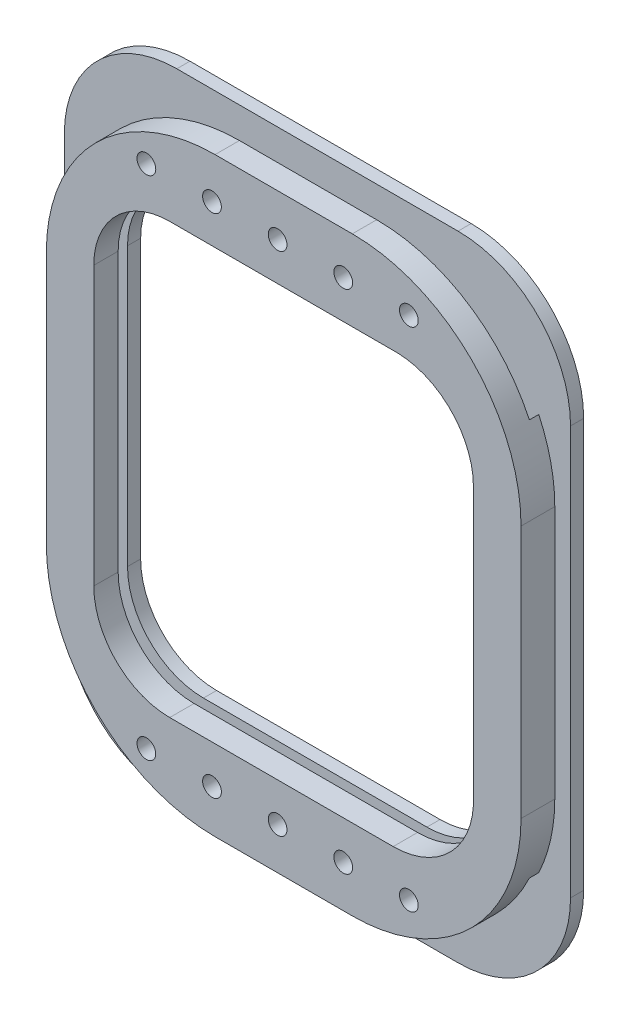
from build123d import *

# Parameters (mm, degrees)
BOSS_EXTRUDE1_DEPTH       = 63.5
SKETCH4_W                 = 299.849109537
SKETCH4_H                 = 429.26
CUT_EXTRUDE2_DEPTH        = 5.08
CUT_EXTRUDE2_DEPTH_BACK   = 1.27
CUT_EXTRUDE4_DEPTH        = 25.4
CUT_EXTRUDE5_START        = -1
SKETCH10_R                = 6.35
CUT_EXTRUDE5_DEPTH        = 120.38
LPATTERN1_COUNT           = 5
LPATTERN1_PITCH           = 44.45
MIRROR1_START             = -1
MIRROR1_COPY_1_SKETCH_R   = 6.35
MIRROR1_COPY_1_DEPTH      = 120.38
MIRROR1_COPY_2_SKETCH_R   = 6.35
MIRROR1_COPY_2_DEPTH      = 120.38
MIRROR1_COPY_3_SKETCH_R   = 6.35
MIRROR1_COPY_3_DEPTH      = 120.38
MIRROR1_COPY_4_SKETCH_R   = 6.35
MIRROR1_COPY_4_DEPTH      = 120.38
SKETCH11_W                = 361.999881137
SKETCH11_H                = 453.321085271
CUT_EXTRUDE6_DEPTH        = 32.75
SKETCH13_R                = 6.355145043
BOSS_EXTRUDE2_DEPTH       = 7.62
REVOLVE1_ANGLE            = 180
LPATTERN2_COUNT           = 5
LPATTERN2_PITCH           = 44.45
LPATTERN3_COUNT           = 2
LPATTERN3_PITCH           = 342.9
LPATTERN3_COPY_1_SKETCH_R = 6.355145043
LPATTERN3_COPY_1_DEPTH    = 7.62
LPATTERN3_COPY_2_SKETCH_R = 6.355145043
LPATTERN3_COPY_2_DEPTH    = 7.62
LPATTERN3_COPY_3_SKETCH_R = 6.355145043
LPATTERN3_COPY_3_DEPTH    = 7.62
LPATTERN3_COPY_4_SKETCH_R = 6.355145043
LPATTERN3_COPY_4_DEPTH    = 7.62
LPATTERN3_COPY_5_ANGLE    = 180
LPATTERN3_COPY_6_ANGLE    = 180
LPATTERN3_COPY_7_ANGLE    = 180
LPATTERN3_COPY_8_ANGLE    = 180


with BuildPart() as part:
    # Sketch1 → Boss-Extrude1 (new body)
    with BuildSketch(Plane.XY):
        with BuildLine():
            Line((69.204322144, 274.429330483), (259.704322144, 274.429330483))
            ThreePointArc((259.704322144, 274.429330483), (313.58585887, 252.11086721), (335.904322144, 198.229330483))
            Line((335.904322144, 198.229330483), (335.904322144, -78.630669517))
            ThreePointArc((335.904322144, -78.630669517), (313.58585887, -132.512206243), (259.704322144, -154.830669517))
            Line((259.704322144, -154.830669517), (69.204322144, -154.830669517))
            ThreePointArc((69.204322144, -154.830669517), (15.322785417, -132.512206243), (-6.995677856, -78.630669517))
            Line((-6.995677856, -78.630669517), (-6.995677856, 198.229330483))
            ThreePointArc((-6.995677856, 198.229330483), (15.322785417, 252.11086721), (69.204322144, 274.429330483))
        make_face()
        with BuildLine():
            ThreePointArc((87.238322144, 205.341330483), (50.868284853, 190.276367774), (35.803322144, 153.906330483))
            Line((35.803322144, 153.906330483), (35.803322144, -34.307669517))
            ThreePointArc((35.803322144, -34.307669517), (50.868284853, -70.677706807), (87.238322144, -85.742669517))
            Line((87.238322144, -85.742669517), (238.611964536, -85.742669517))
            ThreePointArc((238.611964536, -85.742669517), (276.032747747, -70.846230317), (292.978322144, -34.307669517))
            Line((292.978322144, -34.307669517), (292.978322144, 152.678109907))
            ThreePointArc((292.978322144, 152.678109907), (277.986191222, 189.484950394), (241.543322144, 205.341330483))
            Line((241.543322144, 205.341330483), (87.238322144, 205.341330483))
        make_face(mode=Mode.SUBTRACT)
    extrude(amount=BOSS_EXTRUDE1_DEPTH)

    # Sketch4 → Cut-Extrude2 (cut, two sides)
    with BuildSketch(Plane.XY.offset(10.16)) as cut_extrude2_sk:
        with Locations((164.454322144, 59.799330483)):
            Rectangle(SKETCH4_W, SKETCH4_H)
    extrude(amount=CUT_EXTRUDE2_DEPTH, mode=Mode.SUBTRACT)
    extrude(cut_extrude2_sk.sketch, amount=-CUT_EXTRUDE2_DEPTH_BACK, mode=Mode.SUBTRACT)

    # Sketch9 → Cut-Extrude4 (cut)
    with BuildSketch(Plane.XY.offset(8.89)):
        with BuildLine():
            Line((69.204322144, -154.830669517), (259.704322144, -154.830669517))
            ThreePointArc((259.704322144, -154.830669517), (313.58585887, -132.512206243), (335.904322144, -78.630669517))
            Line((335.904322144, -78.630669517), (335.904322144, 198.229330483))
            ThreePointArc((335.904322144, 198.229330483), (313.58585887, 252.11086721), (259.704322144, 274.429330483))
            Line((259.704322144, 274.429330483), (69.204322144, 274.429330483))
            ThreePointArc((69.204322144, 274.429330483), (15.322785417, 252.11086721), (-6.995677856, 198.229330483))
            Line((-6.995677856, 198.229330483), (-6.995677856, -78.630669517))
            ThreePointArc((-6.995677856, -78.630669517), (15.322785417, -132.512206243), (69.204322144, -154.830669517))
        make_face()
        with BuildLine():
            Line((117.972322144, -140.285692494), (210.936322144, -140.285692494))
            ThreePointArc((210.936322144, -140.285692494), (291.758627233, -106.807997584), (325.236322144, -25.985692494))
            Line((325.236322144, -25.985692494), (325.236322144, 145.584353461))
            ThreePointArc((325.236322144, 145.584353461), (291.758627233, 226.406658551), (210.936322144, 259.884353461))
            Line((210.936322144, 259.884353461), (117.972322144, 259.884353461))
            ThreePointArc((117.972322144, 259.884353461), (37.150017054, 226.406658551), (3.672322144, 145.584353461))
            Line((3.672322144, 145.584353461), (3.672322144, -25.985692494))
            ThreePointArc((3.672322144, -25.985692494), (37.150017054, -106.807997584), (117.972322144, -140.285692494))
        make_face(mode=Mode.SUBTRACT)
    extrude(amount=CUT_EXTRUDE4_DEPTH, mode=Mode.SUBTRACT)

    # Sketch10 → Cut-Extrude5 (cut)
    with BuildSketch(Plane.XY.offset(CUT_EXTRUDE5_START)):
        with Locations((249.239313911, 231.249330483)):
            Circle(SKETCH10_R)
    cut_extrude5 = extrude(amount=CUT_EXTRUDE5_DEPTH, mode=Mode.SUBTRACT)

    # LPattern1: Cut-Extrude5 ×5
    with Locations(*[(-i * LPATTERN1_PITCH, 0, 0) for i in range(1, LPATTERN1_COUNT)]):
        add(cut_extrude5, mode=Mode.SUBTRACT)

    # Mirror1: Cut-Extrude5 across plane
    add(cut_extrude5.mirror(Plane.ZX.offset(59.69)), mode=Mode.SUBTRACT)

    # Mirror1 copy 1 sketch → Mirror1 copy 1 (cut)
    with BuildSketch(Plane(origin=(-44.45, 119.38, 0), x_dir=(1, 0, 0), z_dir=(0, 0, 1)).offset(MIRROR1_START)):
        with Locations((249.239313911, -231.249330483)):
            Circle(MIRROR1_COPY_1_SKETCH_R)
    extrude(amount=MIRROR1_COPY_1_DEPTH, mode=Mode.SUBTRACT)

    # Mirror1 copy 2 sketch → Mirror1 copy 2 (cut)
    with BuildSketch(Plane(origin=(-88.9, 119.38, 0), x_dir=(1, 0, 0), z_dir=(0, 0, 1)).offset(MIRROR1_START)):
        with Locations((249.239313911, -231.249330483)):
            Circle(MIRROR1_COPY_2_SKETCH_R)
    extrude(amount=MIRROR1_COPY_2_DEPTH, mode=Mode.SUBTRACT)

    # Mirror1 copy 3 sketch → Mirror1 copy 3 (cut)
    with BuildSketch(Plane(origin=(-133.35, 119.38, 0), x_dir=(1, 0, 0), z_dir=(0, 0, 1)).offset(MIRROR1_START)):
        with Locations((249.239313911, -231.249330483)):
            Circle(MIRROR1_COPY_3_SKETCH_R)
    extrude(amount=MIRROR1_COPY_3_DEPTH, mode=Mode.SUBTRACT)

    # Mirror1 copy 4 sketch → Mirror1 copy 4 (cut)
    with BuildSketch(Plane(origin=(-177.8, 119.38, 0), x_dir=(1, 0, 0), z_dir=(0, 0, 1)).offset(MIRROR1_START)):
        with Locations((249.239313911, -231.249330483)):
            Circle(MIRROR1_COPY_4_SKETCH_R)
    extrude(amount=MIRROR1_COPY_4_DEPTH, mode=Mode.SUBTRACT)

    # Sketch11 → Cut-Extrude6 (cut, through all)
    with BuildSketch(Plane(origin=(0, 0, 31.75), x_dir=(-1, 0, 0), z_dir=(0, 0, -1))):
        with Locations((-165.439802764, 61.770291724)):
            Rectangle(SKETCH11_W, SKETCH11_H)
    extrude(amount=-CUT_EXTRUDE6_DEPTH, mode=Mode.SUBTRACT)

    # Sketch13 → Boss-Extrude2 (add)
    with BuildSketch(Plane(origin=(0, 0, 0), x_dir=(-1, 0, 0), z_dir=(0, 0, -1))):
        with Locations((-249.244225601, 231.2508624)):
            Circle(SKETCH13_R)
    boss_extrude2 = extrude(amount=-BOSS_EXTRUDE2_DEPTH)

    # Sketch14 → Revolve1 (revolve)
    with BuildSketch(Plane(origin=(0, 0, 0), x_dir=(-1, 0, 0), z_dir=(0, 0, -1))):
        with BuildLine():
            Line((-255.848225601, 231.2508624), (-242.640225601, 231.2508624))
            ThreePointArc((-242.640225601, 231.2508624), (-249.244225601, 237.8548624), (-255.848225601, 231.2508624))
        make_face()
    revolve1 = revolve(axis=Axis((255.848225601, 231.2508624, 0), (-1, 0, 0)), revolution_arc=REVOLVE1_ANGLE)

    # LPattern2: Boss-Extrude2, Revolve1 ×5
    with Locations(*[(-i * LPATTERN2_PITCH, 0, 0) for i in range(1, LPATTERN2_COUNT)]):
        add(boss_extrude2)
        add(revolve1)

    # LPattern3: Revolve1, Boss-Extrude2 ×2
    with Locations(*[(0, -i * LPATTERN3_PITCH, 0) for i in range(1, LPATTERN3_COUNT)]):
        add(revolve1)
        add(boss_extrude2)

    # LPattern3 copy 1 sketch → LPattern3 copy 1 (add)
    with BuildSketch(Plane(origin=(-44.45, -342.9, 0), x_dir=(-1, 0, 0), z_dir=(0, 0, -1))):
        with Locations((-249.244225601, 231.2508624)):
            Circle(LPATTERN3_COPY_1_SKETCH_R)
    extrude(amount=-LPATTERN3_COPY_1_DEPTH)

    # LPattern3 copy 2 sketch → LPattern3 copy 2 (add)
    with BuildSketch(Plane(origin=(-88.9, -342.9, 0), x_dir=(-1, 0, 0), z_dir=(0, 0, -1))):
        with Locations((-249.244225601, 231.2508624)):
            Circle(LPATTERN3_COPY_2_SKETCH_R)
    extrude(amount=-LPATTERN3_COPY_2_DEPTH)

    # LPattern3 copy 3 sketch → LPattern3 copy 3 (add)
    with BuildSketch(Plane(origin=(-133.35, -342.9, 0), x_dir=(-1, 0, 0), z_dir=(0, 0, -1))):
        with Locations((-249.244225601, 231.2508624)):
            Circle(LPATTERN3_COPY_3_SKETCH_R)
    extrude(amount=-LPATTERN3_COPY_3_DEPTH)

    # LPattern3 copy 4 sketch → LPattern3 copy 4 (add)
    with BuildSketch(Plane(origin=(-177.8, -342.9, 0), x_dir=(-1, 0, 0), z_dir=(0, 0, -1))):
        with Locations((-249.244225601, 231.2508624)):
            Circle(LPATTERN3_COPY_4_SKETCH_R)
    extrude(amount=-LPATTERN3_COPY_4_DEPTH)

    # LPattern3 copy 5 sketch → LPattern3 copy 5 (revolve)
    with BuildSketch(Plane(origin=(-44.45, -342.9, 0), x_dir=(-1, 0, 0), z_dir=(0, 0, -1))):
        with BuildLine():
            Line((-255.848225601, 231.2508624), (-242.640225601, 231.2508624))
            ThreePointArc((-242.640225601, 231.2508624), (-249.244225601, 237.8548624), (-255.848225601, 231.2508624))
        make_face()
    revolve(axis=Axis((211.398225601, -111.6491376, 0), (-1, 0, 0)), revolution_arc=LPATTERN3_COPY_5_ANGLE)

    # LPattern3 copy 6 sketch → LPattern3 copy 6 (revolve)
    with BuildSketch(Plane(origin=(-88.9, -342.9, 0), x_dir=(-1, 0, 0), z_dir=(0, 0, -1))):
        with BuildLine():
            Line((-255.848225601, 231.2508624), (-242.640225601, 231.2508624))
            ThreePointArc((-242.640225601, 231.2508624), (-249.244225601, 237.8548624), (-255.848225601, 231.2508624))
        make_face()
    revolve(axis=Axis((166.948225601, -111.6491376, 0), (-1, 0, 0)), revolution_arc=LPATTERN3_COPY_6_ANGLE)

    # LPattern3 copy 7 sketch → LPattern3 copy 7 (revolve)
    with BuildSketch(Plane(origin=(-133.35, -342.9, 0), x_dir=(-1, 0, 0), z_dir=(0, 0, -1))):
        with BuildLine():
            Line((-255.848225601, 231.2508624), (-242.640225601, 231.2508624))
            ThreePointArc((-242.640225601, 231.2508624), (-249.244225601, 237.8548624), (-255.848225601, 231.2508624))
        make_face()
    revolve(axis=Axis((122.498225601, -111.6491376, 0), (-1, 0, 0)), revolution_arc=LPATTERN3_COPY_7_ANGLE)

    # LPattern3 copy 8 sketch → LPattern3 copy 8 (revolve)
    with BuildSketch(Plane(origin=(-177.8, -342.9, 0), x_dir=(-1, 0, 0), z_dir=(0, 0, -1))):
        with BuildLine():
            Line((-255.848225601, 231.2508624), (-242.640225601, 231.2508624))
            ThreePointArc((-242.640225601, 231.2508624), (-249.244225601, 237.8548624), (-255.848225601, 231.2508624))
        make_face()
    revolve(axis=Axis((78.048225601, -111.6491376, 0), (-1, 0, 0)), revolution_arc=LPATTERN3_COPY_8_ANGLE)


solid = part.part
